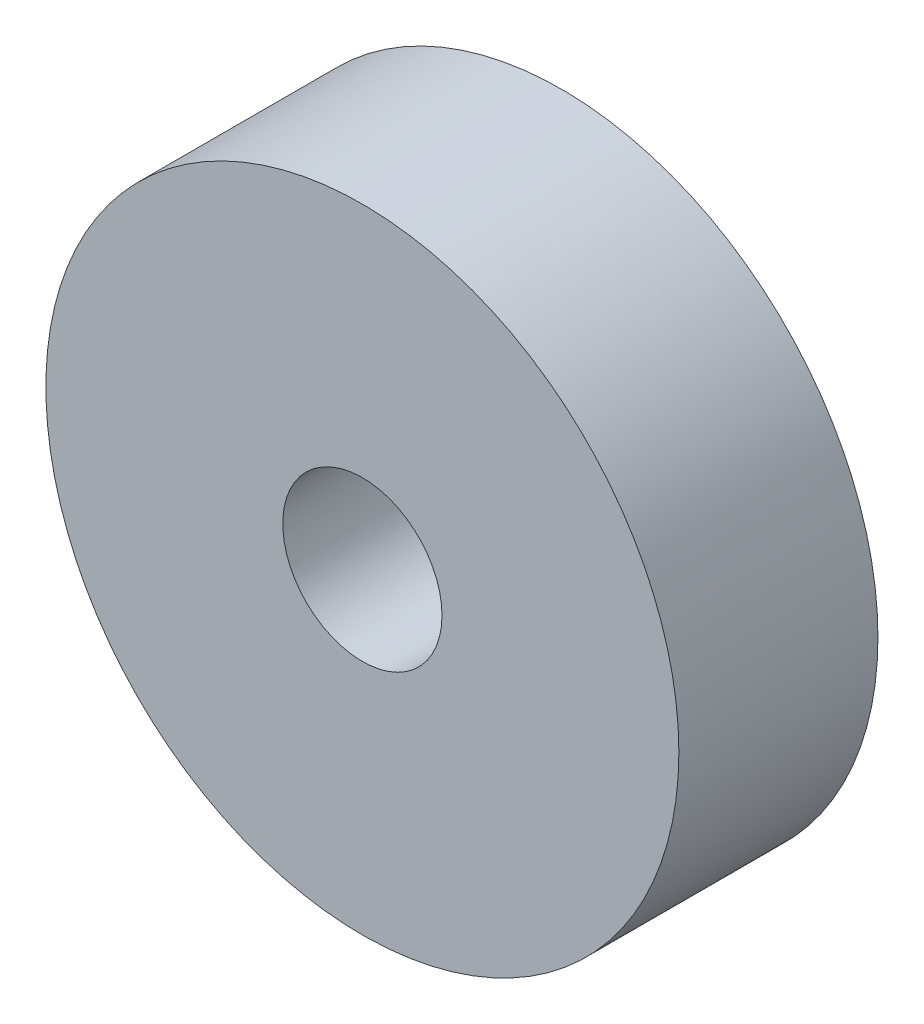
from build123d import *

# Parameters (mm, degrees)
ESQUISSE1_R        = 15.9
ESQUISSE1_R_2      = 4
BOSS_EXTRU_1_DEPTH = 10


with BuildPart() as part:
    # Esquisse1 → Boss.-Extru.1 (new body)
    with BuildSketch(Plane.XY):
        with Locations((37.944866713, 25.352320867)):
            Circle(ESQUISSE1_R)
        with Locations((37.944866713, 25.352320867)):
            Circle(ESQUISSE1_R_2, mode=Mode.SUBTRACT)
    extrude(amount=BOSS_EXTRU_1_DEPTH)


solid = part.part
